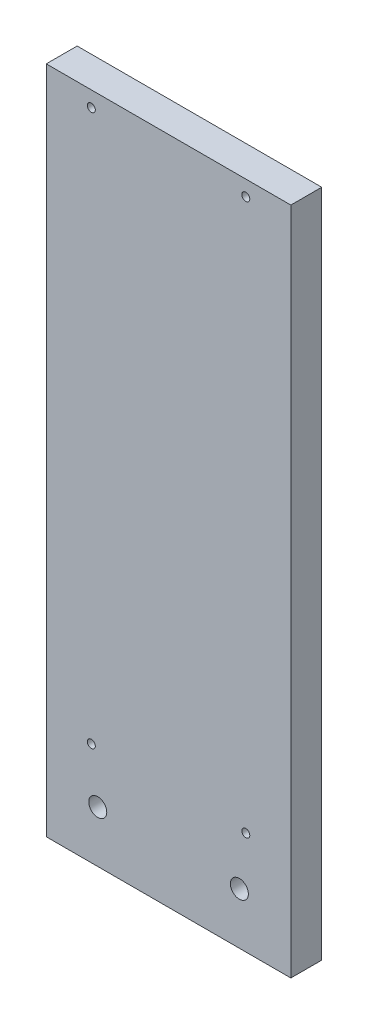
from build123d import *

# Parameters (mm, degrees)
SKETCH1_W           = 95
SKETCH1_H           = 260
BOSS_EXTRUDE1_DEPTH = 12
SKETCH3_R           = 3.5
CUT_EXTRUDE1_DEPTH  = 13
SKETCH4_R           = 1.55
CUT_EXTRUDE2_DEPTH  = 13


with BuildPart() as part:
    # Sketch1 → Boss-Extrude1 (new body)
    with BuildSketch(Plane.XY):
        Rectangle(SKETCH1_W, SKETCH1_H)
    extrude(amount=BOSS_EXTRUDE1_DEPTH)

    # Sketch3 → Cut-Extrude1 (cut, through all)
    with BuildSketch(Plane.XY.offset(12)):
        with Locations((-27.5, -110)):
            Circle(SKETCH3_R)
        with Locations((27.5, -110)):
            Circle(SKETCH3_R)
    extrude(amount=-CUT_EXTRUDE1_DEPTH, mode=Mode.SUBTRACT)

    # Sketch4 → Cut-Extrude2 (cut, through all)
    with BuildSketch(Plane.XY.offset(12)):
        with Locations((-30, -90)):
            Circle(SKETCH4_R)
        with Locations((30, -90)):
            Circle(SKETCH4_R)
        with Locations((30, 124)):
            Circle(SKETCH4_R)
        with Locations((-30, 124)):
            Circle(SKETCH4_R)
    extrude(amount=-CUT_EXTRUDE2_DEPTH, mode=Mode.SUBTRACT)


solid = part.part
